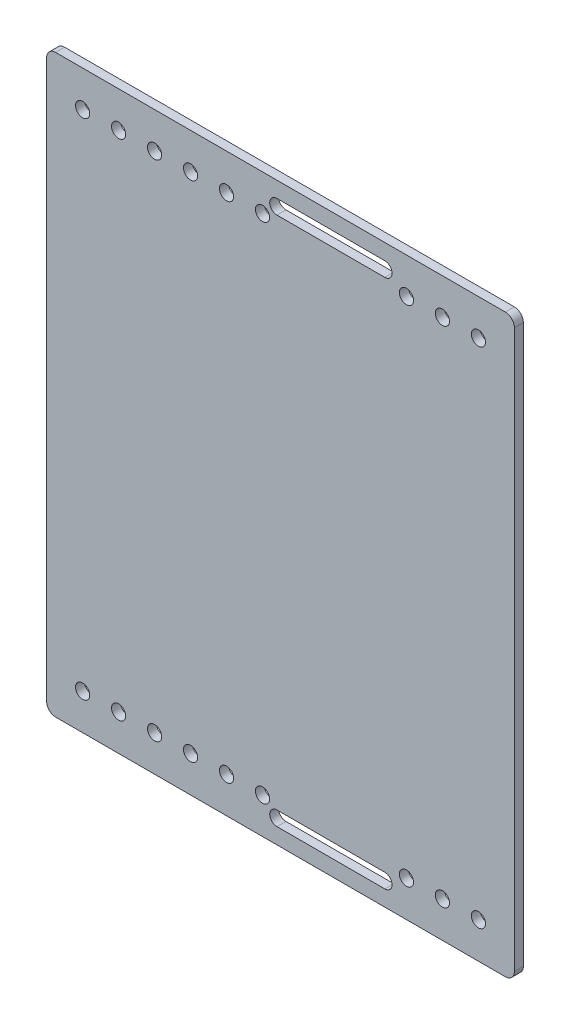
from build123d import *

# Parameters (mm, degrees)
BOSS_EXTRUDE1_DEPTH = 3.175
SKETCH3_R           = 2.505
CUT_EXTRUDE4_DEPTH  = 4.175


with BuildPart() as part:
    # Sketch1 → Boss-Extrude1 (new body)
    with BuildSketch(Plane.XY):
        with BuildLine():
            Line((-227.394146502, -79.607268705), (-386.144146502, -79.607268705))
            ThreePointArc((-386.144146502, -79.607268705), (-388.389210532, -78.677332735), (-389.319146502, -76.432268705))
            Line((-389.319146502, -76.432268705), (-389.319146502, 120.417731295))
            ThreePointArc((-389.319146502, 120.417731295), (-388.389210532, 122.662795325), (-386.144146502, 123.592731295))
            Line((-386.144146502, 123.592731295), (-227.394146502, 123.592731295))
            ThreePointArc((-227.394146502, 123.592731295), (-225.149082471, 122.662795325), (-224.219146502, 120.417731295))
            Line((-224.219146502, 120.417731295), (-224.219146502, -76.432268705))
            ThreePointArc((-224.219146502, -76.432268705), (-225.149082471, -78.677332735), (-227.394146502, -79.607268705))
        make_face()
        with BuildLine():
            Line((-308.039146502, 118.004731295), (-269.939146502, 118.004731295))
            ThreePointArc((-269.939146502, 118.004731295), (-267.399146502, 115.464731295), (-269.939146502, 112.924731295))
            Line((-269.939146502, 112.924731295), (-308.039146502, 112.924731295))
            ThreePointArc((-308.039146502, 112.924731295), (-310.579146502, 115.464731295), (-308.039146502, 118.004731295))
        make_face(mode=Mode.SUBTRACT)
        with BuildLine():
            Line((-308.039146502, -68.939268705), (-269.939146502, -68.939268705))
            ThreePointArc((-269.939146502, -68.939268705), (-267.399146502, -71.479268705), (-269.939146502, -74.019268705))
            Line((-269.939146502, -74.019268705), (-308.039146502, -74.019268705))
            ThreePointArc((-308.039146502, -74.019268705), (-310.579146502, -71.479268705), (-308.039146502, -68.939268705))
        make_face(mode=Mode.SUBTRACT)
    extrude(amount=BOSS_EXTRUDE1_DEPTH)

    # Sketch3 → Cut-Extrude4 (cut, through all)
    with BuildSketch(Plane.XY.offset(3.175)):
        with Locations((-376.619146502, 110.892731295)):
            Circle(SKETCH3_R)
        with Locations((-376.619146502, -66.907268705)):
            Circle(SKETCH3_R)
        with Locations((-363.919146502, 110.892731295)):
            Circle(SKETCH3_R)
        with Locations((-363.919146502, -66.907268705)):
            Circle(SKETCH3_R)
        with Locations((-351.219146502, 110.892731295)):
            Circle(SKETCH3_R)
        with Locations((-351.219146502, -66.907268705)):
            Circle(SKETCH3_R)
        with Locations((-338.519146502, 110.892731295)):
            Circle(SKETCH3_R)
        with Locations((-338.519146502, -66.907268705)):
            Circle(SKETCH3_R)
        with Locations((-325.819146502, 110.892731295)):
            Circle(SKETCH3_R)
        with Locations((-325.819146502, -66.907268705)):
            Circle(SKETCH3_R)
        with Locations((-313.119146502, 110.892731295)):
            Circle(SKETCH3_R)
        with Locations((-313.119146502, -66.907268705)):
            Circle(SKETCH3_R)
        with Locations((-236.919146502, 110.892731295)):
            Circle(SKETCH3_R)
        with Locations((-236.919146502, -66.907268705)):
            Circle(SKETCH3_R)
        with Locations((-249.619146502, -66.907268705)):
            Circle(SKETCH3_R)
        with Locations((-249.619146502, 110.892731295)):
            Circle(SKETCH3_R)
        with Locations((-262.319146502, -66.907268705)):
            Circle(SKETCH3_R)
        with Locations((-262.319146502, 110.892731295)):
            Circle(SKETCH3_R)
    extrude(amount=-CUT_EXTRUDE4_DEPTH, mode=Mode.SUBTRACT)


solid = part.part
